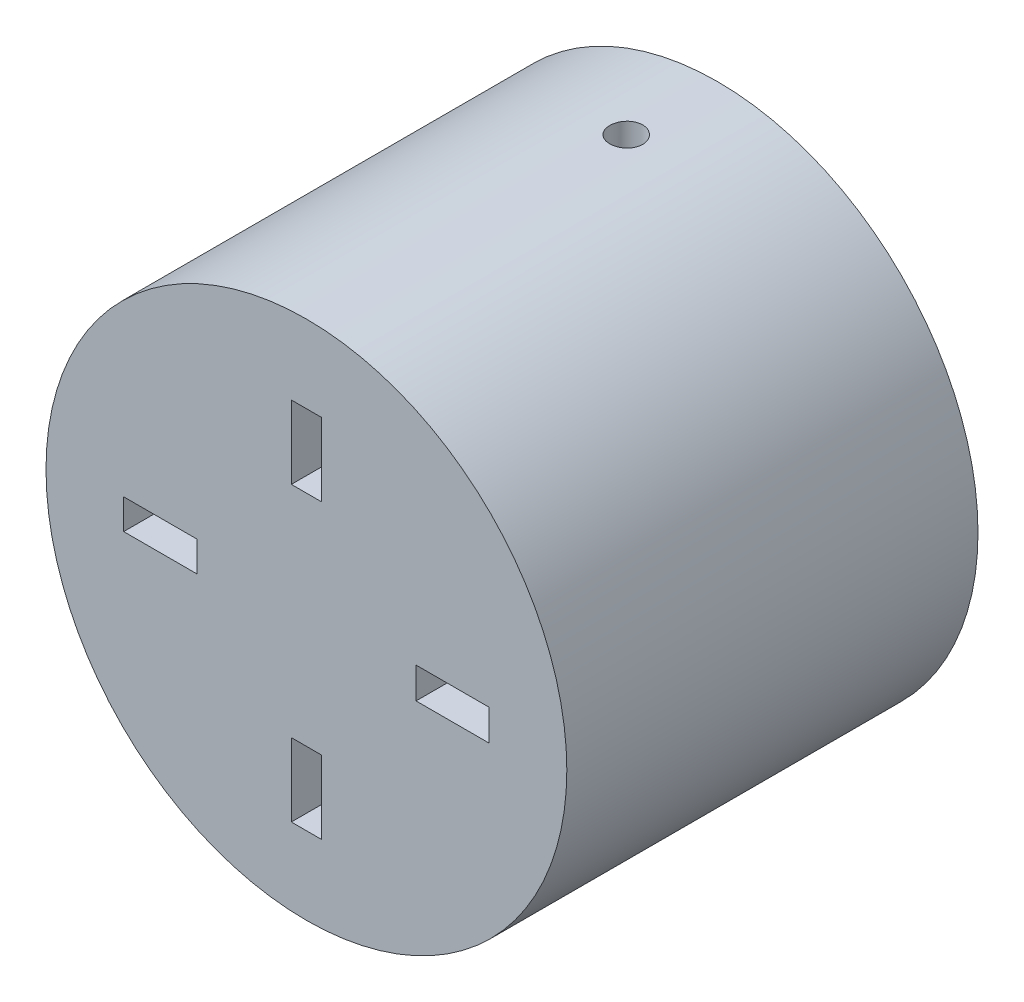
from build123d import *

# Parameters (mm, degrees)
SKETCH1_R           = 28.5
SKETCH1_W           = 3.3
SKETCH1_H           = 8
SKETCH1_W_2         = 8
SKETCH1_H_2         = 3.3
SKETCH1_H_3         = 3.4
BOSS_EXTRUDE1_DEPTH = 5
SKETCH1_3_R         = 28.5
BOSS_EXTRUDE2_DEPTH = 40
SKETCH2_R           = 1.8
CUT_EXTRUDE1_DEPTH  = 35


with BuildPart() as part:
    # Sketch1 → Boss-Extrude1 (new body)
    with BuildSketch(Plane.XY):
        Circle(SKETCH1_R)
        with Locations((0, 16)):
            Rectangle(SKETCH1_W, SKETCH1_H, mode=Mode.SUBTRACT)
        with Locations((-16, 0)):
            Rectangle(SKETCH1_W_2, SKETCH1_H_2, mode=Mode.SUBTRACT)
        with Locations((0, -16)):
            Rectangle(SKETCH1_W, SKETCH1_H, mode=Mode.SUBTRACT)
        with Locations((16, 0)):
            Rectangle(SKETCH1_W_2, SKETCH1_H_3, mode=Mode.SUBTRACT)
    extrude(amount=BOSS_EXTRUDE1_DEPTH)


with BuildPart() as body_2:
    # Sketch1_3 → Boss-Extrude2 (new body)
    with BuildSketch(Plane.XY):
        Circle(SKETCH1_3_R)
        with BuildLine():
            Line((-5.65, 19.706026997), (-5.65, 24))
            Line((-5.65, 24), (5.65, 24))
            Line((5.65, 24), (5.65, 19.706026997))
            ThreePointArc((5.65, 19.706026997), (14.477280714, 14.514073968), (19.691622584, 5.7))
            Line((19.691622584, 5.7), (24, 5.7))
            Line((24, 5.7), (24, -5.7))
            Line((24, -5.7), (19.691622584, -5.7))
            ThreePointArc((19.691622584, -5.7), (14.477280714, -14.514073968), (5.65, -19.706026997))
            Line((5.65, -19.706026997), (5.65, -24))
            Line((5.65, -24), (-5.65, -24))
            Line((-5.65, -24), (-5.65, -19.706026997))
            ThreePointArc((-5.65, -19.706026997), (-14.495689014, -14.495689014), (-19.706026997, -5.65))
            Line((-19.706026997, -5.65), (-24, -5.65))
            Line((-24, -5.65), (-24, 5.65))
            Line((-24, 5.65), (-19.706026997, 5.65))
            ThreePointArc((-19.706026997, 5.65), (-14.495689014, 14.495689014), (-5.65, 19.706026997))
        make_face(mode=Mode.SUBTRACT)
    extrude(amount=-BOSS_EXTRUDE2_DEPTH)

    # Combine1: union part
    add(part.part)

    # Sketch2 → Cut-Extrude1 (cut, symmetric)
    with BuildSketch(Plane(origin=(0, 0, 0), x_dir=(1, 0, 0), z_dir=(0, 1, 0))):
        with Locations((0, 30)):
            Circle(SKETCH2_R)
    extrude(amount=CUT_EXTRUDE1_DEPTH, both=True, mode=Mode.SUBTRACT)


solid = body_2.part
